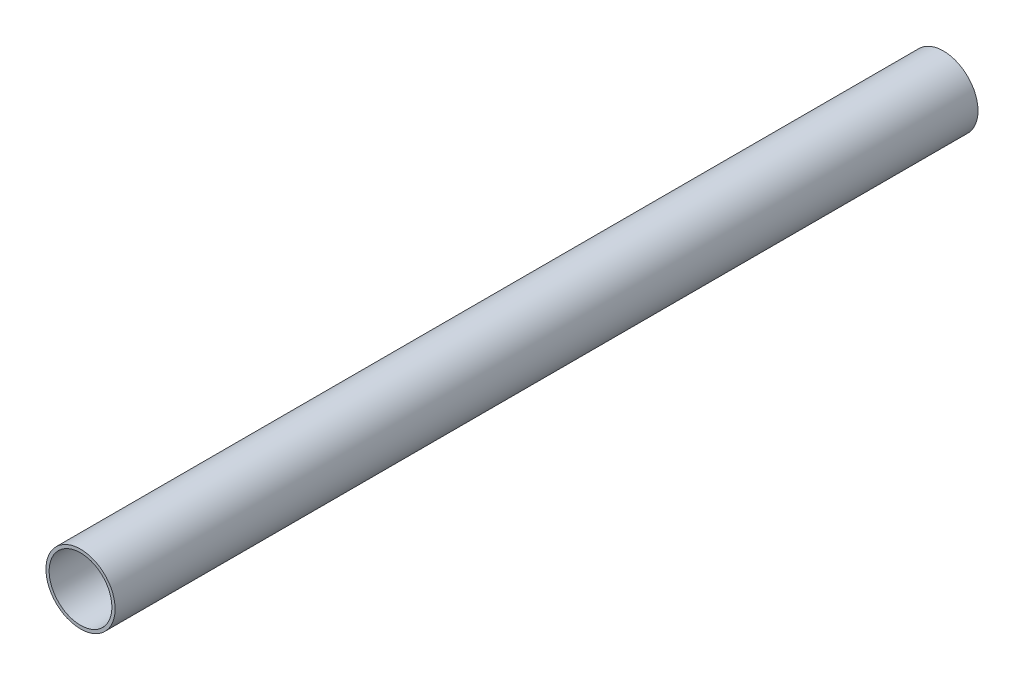
from build123d import *

# Parameters (mm, degrees)
SKETCH3_R               = 11.022655214
BOSS_EXTRUDE1_DEPTH     = 275
CUT_EXTRUDE1_DEPTH      = 275
CUT_EXTRUDE1_DEPTH_BACK = 275
SKETCH2_R               = 10


with BuildPart() as part:
    # Sketch3 → Boss-Extrude1 (new body)
    with BuildSketch(Plane.XY):
        Circle(SKETCH3_R)
    extrude(amount=BOSS_EXTRUDE1_DEPTH)

    # Sketch2 → Cut-Extrude1 (cut, two sides: drawn at the far end of the back side and taken through both)
    with BuildSketch(Plane.XY.offset(-CUT_EXTRUDE1_DEPTH_BACK)):
        Circle(SKETCH2_R)
    extrude(amount=CUT_EXTRUDE1_DEPTH + CUT_EXTRUDE1_DEPTH_BACK, mode=Mode.SUBTRACT)


solid = part.part
